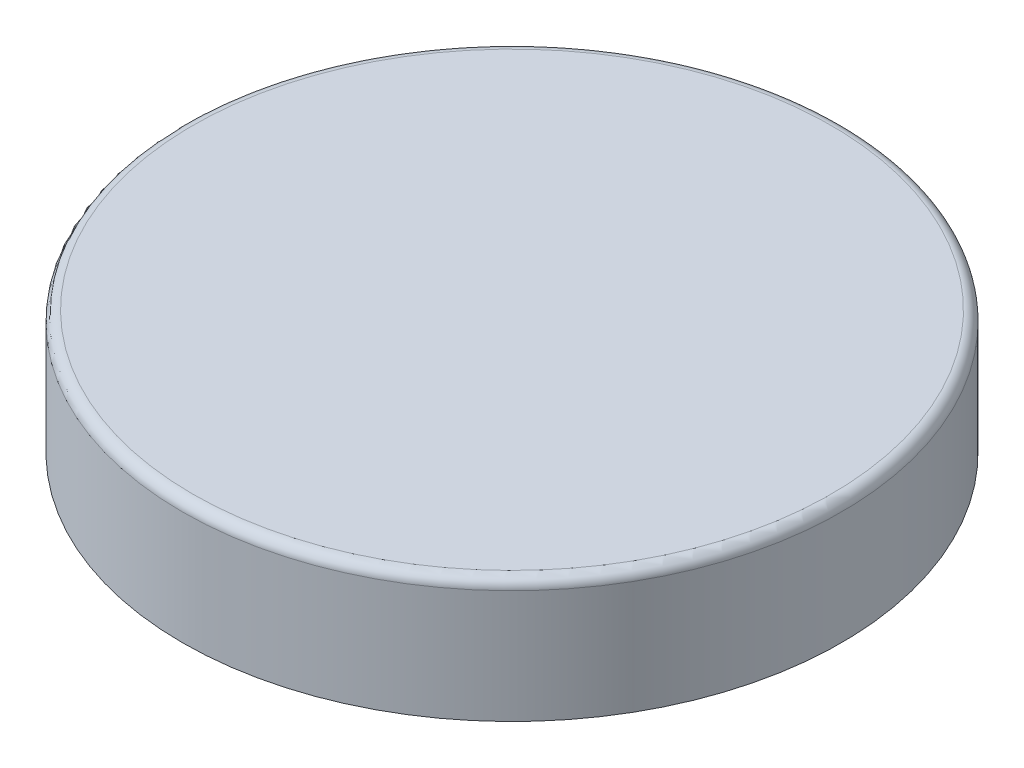
from build123d import *

# Parameters (mm, degrees)
FILLET1_R = 0.79375


with BuildPart() as part:
    # Sketch1 → Revolve1 (revolve)
    with BuildSketch(Plane(origin=(0, 0, 0), x_dir=(0, 0, -1), z_dir=(1, 0, 0))):
        Polygon((0, 4.7625), (25.4, 4.7625), (25.4, -4.7625), (22.225, -4.7625), (22.225, 1.5875), (0, 1.5875), align=None)
    revolve(axis=Axis((0, -32.325211936, 0), (0, 1, 0)))

    # Fillet1
    fillet1_edges = [part.edges().sort_by_distance(p)[0] for p in [
        (0, 1.5875, 22.225),
        (0, -4.7625, 22.225),
        (0, 4.7625, 25.4),
    ]]
    fillet(fillet1_edges, radius=FILLET1_R)


solid = part.part
